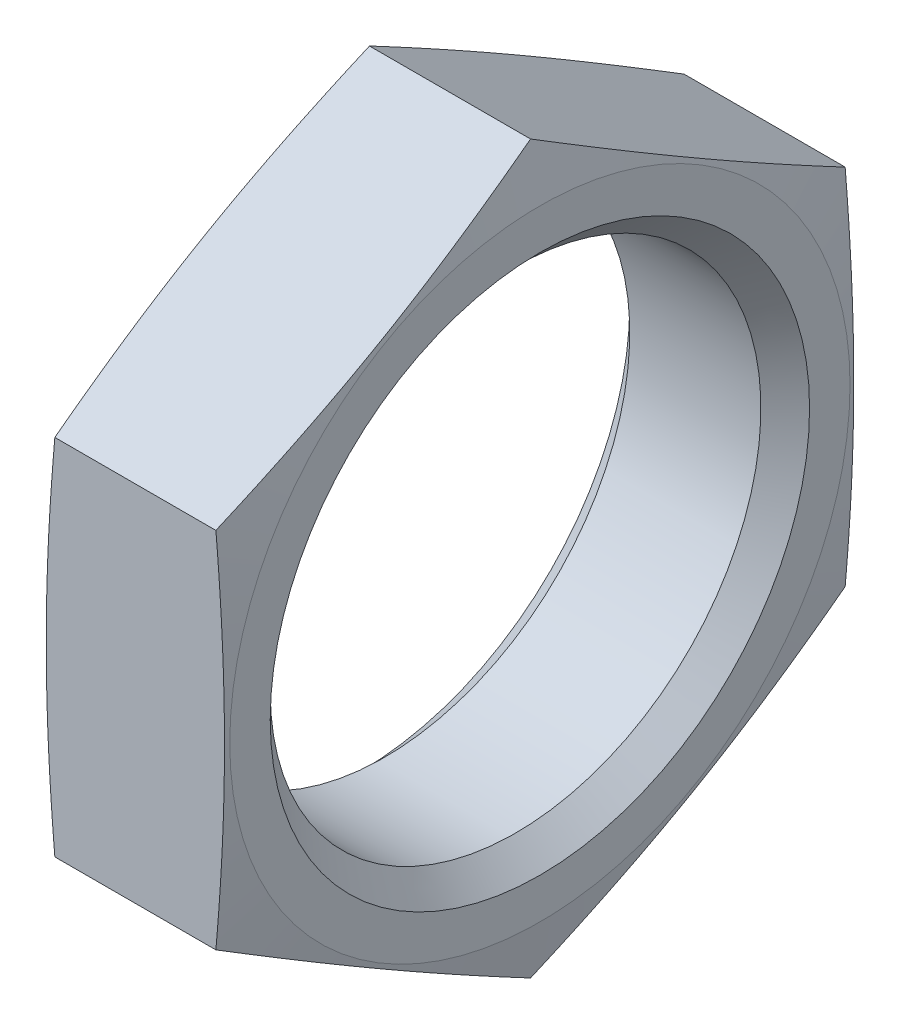
from build123d import *

# Parameters (mm, degrees)
SKETCH3_W          = 28
SKETCH3_H          = 28
CUT_EXTRUDE1_DEPTH = 4


with BuildPart() as part:
    # Sketch1 → Revolve1 (revolve)
    with BuildSketch(Plane.XY):
        Polygon((0, 0), (0, 6.9), (0.511348244, 9.8), (3.488651756, 9.8), (4, 6.9), (4, 0), align=None)
    revolve(axis=Axis((4, 0, 0), (-1, 0, 0)))

    # Sketch2 → Cut-Revolve1 (revolve, cut)
    with BuildSketch(Plane.XY):
        Polygon((0, 0), (0, 6), (0.5415, 5.4585), (3.4585, 5.4585), (4, 6), (4, 0), align=None)
    revolve(axis=Axis((4, 0, 0), (-1, 0, 0)), mode=Mode.SUBTRACT)

    # Sketch3 → Cut-Extrude1 (cut)
    with BuildSketch(Plane(origin=(0, 0, 0), x_dir=(0, 0, -1), z_dir=(1, 0, 0))):
        Rectangle(SKETCH3_W, SKETCH3_H)
        Polygon((-7, -4.041451884), (0, -8.082903769), (7, -4.041451884), (7, 4.041451884), (0, 8.082903769), (-7, 4.041451884), align=None, mode=Mode.SUBTRACT)
    extrude(amount=CUT_EXTRUDE1_DEPTH, mode=Mode.SUBTRACT)


solid = part.part
